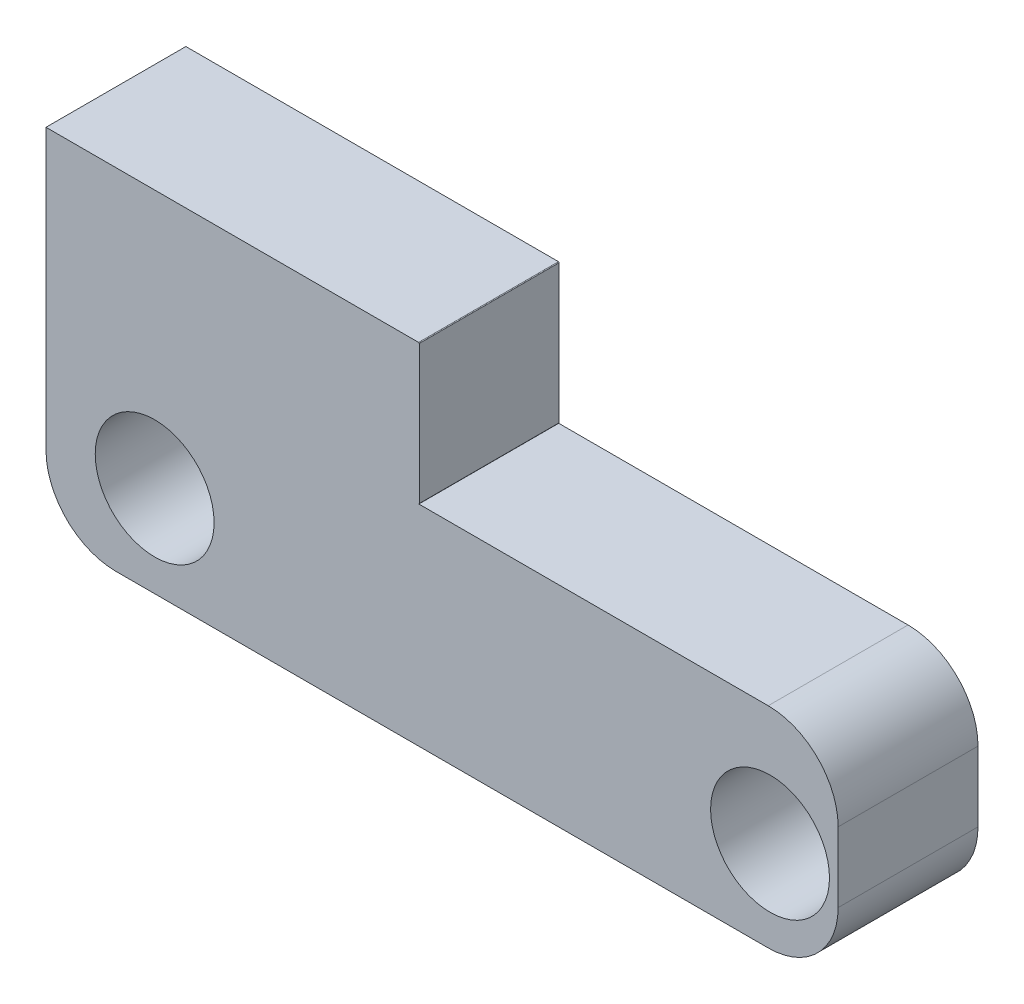
from build123d import *

# Parameters (mm, degrees)
RESSALTO_EXTRUS_O1_DEPTH = 10
ESBO_O2_W                = 26.639233333
ESBO_O2_H                = 10
RESSALTO_EXTRUS_O2_DEPTH = 15
ESBO_O3_W                = 10
ESBO_O3_H                = 15
RESSALTO_EXTRUS_O3_DEPTH = 30
ESBO_O4_R                = 4.25
CORTE_EXTRUS_O1_DEPTH    = 30
FILETE1_R                = 5


with BuildPart() as part:
    # Esboço1 → Ressalto-extrusão1 (new body)
    with BuildSketch(Plane.XY):
        with BuildLine():
            Line((-26.689233333, 0), (-26.689233333, 10))
            Line((-26.689233333, 10), (-0.05, 10))
            ThreePointArc((-0.05, 10), (-0.014644661, 9.985355339), (0, 9.95))
            Line((0, 9.95), (0, 0.05))
            ThreePointArc((0, 0.05), (-0.014644661, 0.014644661), (-0.05, 0))
            Line((-0.05, 0), (-26.689233333, 0))
        make_face()
    extrude(amount=RESSALTO_EXTRUS_O1_DEPTH)

    # Esboço2 → Ressalto-extrusão2 (add)
    with BuildSketch(Plane.XZ):
        with Locations((-13.369616667, 5)):
            Rectangle(ESBO_O2_W, ESBO_O2_H)
    extrude(amount=RESSALTO_EXTRUS_O2_DEPTH)

    # Esboço3 → Ressalto-extrusão3 (add)
    with BuildSketch(Plane(origin=(-0.05, 0, 0), x_dir=(0, 0, -1), z_dir=(1, 0, 0))):
        with Locations((-5, -7.5)):
            Rectangle(ESBO_O3_W, ESBO_O3_H)
    extrude(amount=RESSALTO_EXTRUS_O3_DEPTH)

    # Esboço4 → Corte-extrusão1 (cut)
    with BuildSketch(Plane(origin=(0, 0, 0), x_dir=(-1, 0, 0), z_dir=(0, 0, -1))):
        with Locations((-25.08, -8.473337784)):
            Circle(ESBO_O4_R)
        with Locations((18.92, -8.473337784)):
            Circle(ESBO_O4_R)
    extrude(amount=-CORTE_EXTRUS_O1_DEPTH, mode=Mode.SUBTRACT)

    # Filete1
    filete1_edges = [part.edges().sort_by_distance(p)[0] for p in [
        (-26.689233333, -15, 5),
        (29.95, 0, 5),
        (29.95, -15, 5),
    ]]
    fillet(filete1_edges, radius=FILETE1_R)


solid = part.part
